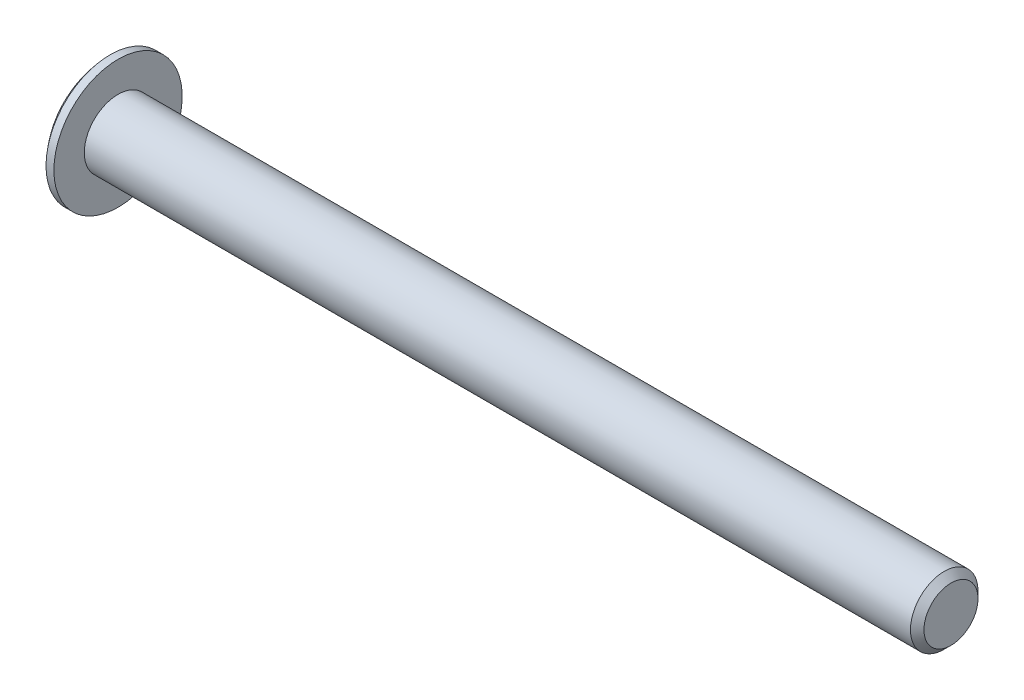
from build123d import *

# Parameters (mm, degrees)
CHAMFER1_SIZE      = 0.6
CUT_EXTRUDE1_DEPTH = 2


with BuildPart() as part:
    # Sketch1 → Revolve1 (revolve)
    with BuildSketch(Plane.XY):
        with BuildLine():
            Line((0, 0), (76.3, 0))
            Line((76.3, 0), (76.3, 3))
            Line((76.3, 3), (2.3, 3))
            Line((2.3, 3), (2.3, 5.7))
            Line((2.3, 5.7), (1.6, 5.7))
            ThreePointArc((1.6, 5.7), (0.632383618, 4.374431764), (0, 2.86))
            Line((0, 2.86), (0, 0))
        make_face()
    revolve(axis=Axis((0, 0, 0), (1, 0, 0)))

    # Chamfer1
    chamfer1_edges = [part.edges().sort_by_distance(p)[0] for p in [
        (76.3, -3, 0),
    ]]
    chamfer(chamfer1_edges, length=CHAMFER1_SIZE)

    # Sketch2 → Cut-Extrude1 (cut)
    with BuildSketch(Plane.ZY):
        Polygon((0, 2.309401077), (-2, 1.154700538), (-2, -1.154700538), (0, -2.309401077), (2, -1.154700538), (2, 1.154700538), align=None)
    extrude(amount=-CUT_EXTRUDE1_DEPTH, mode=Mode.SUBTRACT)


solid = part.part
